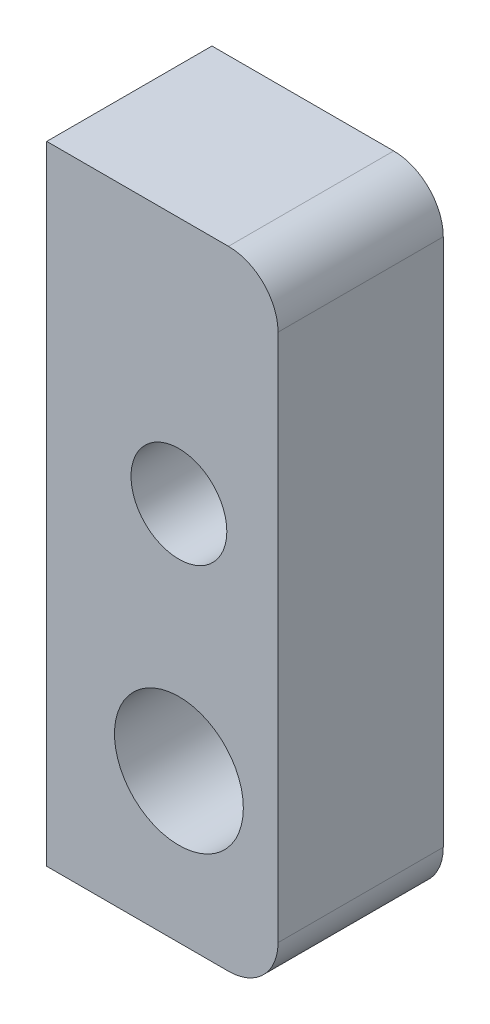
from build123d import *

# Parameters (mm, degrees)
SKETCH1_R           = 1.95
SKETCH1_R_2         = 1.45
BOSS_EXTRUDE2_DEPTH = 5


with BuildPart() as part:
    # Sketch1 → Boss-Extrude2 (new body)
    with BuildSketch(Plane.XY):
        with BuildLine():
            Line((20, -9.5), (20, 9.5))
            Line((20, 9.5), (25.5, 9.5))
            ThreePointArc((25.5, 9.5), (26.560660172, 9.060660172), (27, 8))
            Line((27, 8), (27, -8))
            ThreePointArc((27, -8), (26.560660172, -9.060660172), (25.5, -9.5))
            Line((25.5, -9.5), (20, -9.5))
        make_face()
        with Locations((24, -5)):
            Circle(SKETCH1_R, mode=Mode.SUBTRACT)
        with Locations((24, 2)):
            Circle(SKETCH1_R_2, mode=Mode.SUBTRACT)
    extrude(amount=-BOSS_EXTRUDE2_DEPTH)


solid = part.part
